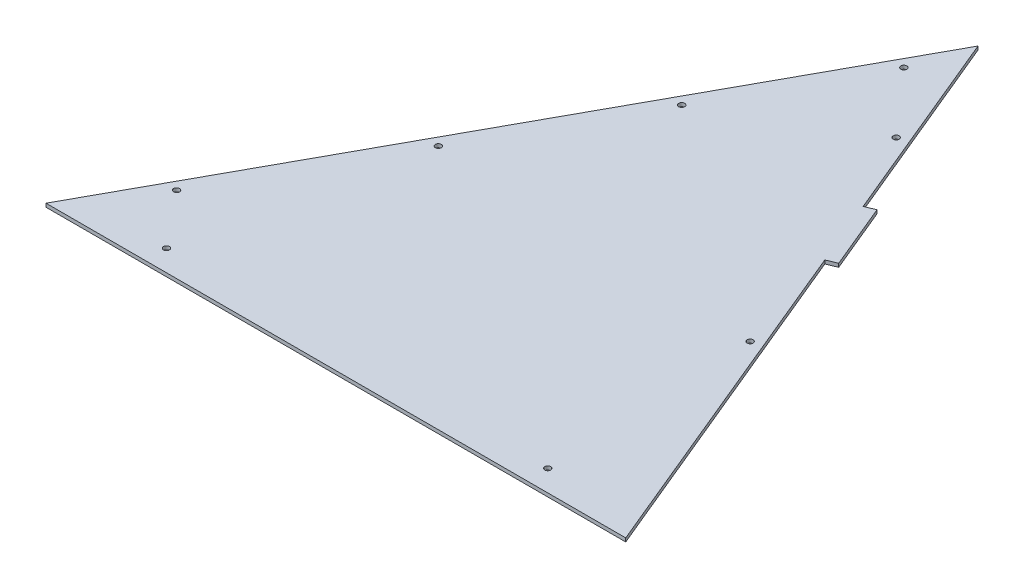
from build123d import *

# Parameters (mm, degrees)
SKETCH4_R           = 5.3578125
BOSS_EXTRUDE2_DEPTH = 6.35


with BuildPart() as part:
    # Sketch4 → Boss-Extrude2 (new body)
    with BuildSketch(Plane(origin=(0, 0, 0), x_dir=(1, 0, 0), z_dir=(0, 1, 0))):
        Polygon((234.979236566, 1078.971634327), (-356.170330123, 0), (682.689669877, 0), (429.674039163, 609.761730508), (381.000338514, 727.064206463), align=None)
        with Locations((-178.370330123, 38.1)):
            Circle(SKETCH4_R, mode=Mode.SUBTRACT)
        with Locations((-259.300975608, 137.16)):
            Circle(SKETCH4_R, mode=Mode.SUBTRACT)
        with Locations((-93.289784566, 440.165155055)):
            Circle(SKETCH4_R, mode=Mode.SUBTRACT)
        with Locations((504.889669877, 38.1)):
            Circle(SKETCH4_R, mode=Mode.SUBTRACT)
        with Locations((489.29326545, 416.375307605)):
            Circle(SKETCH4_R, mode=Mode.SUBTRACT)
        with Locations((61.094542054, 721.948850069)):
            Circle(SKETCH4_R, mode=Mode.SUBTRACT)
        with Locations((303.667495105, 863.729056592)):
            Circle(SKETCH4_R, mode=Mode.SUBTRACT)
        with Locations((201.97392089, 979.083189991)):
            Circle(SKETCH4_R, mode=Mode.SUBTRACT)
        Polygon((429.674039163, 609.761730508), (381.000338514, 727.064206463), (398.595709907, 734.36526156), (447.269410556, 617.062785606), align=None)
    extrude(amount=BOSS_EXTRUDE2_DEPTH)


solid = part.part
